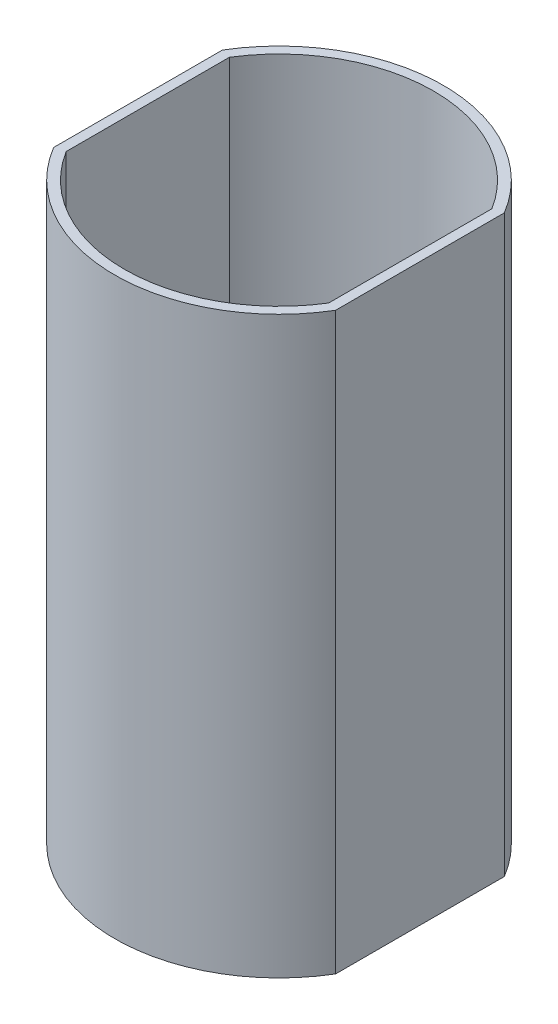
from build123d import *

# Parameters (mm, degrees)
SKETCH1_R           = 30.3
BOSS_EXTRUDE1_DEPTH = 106
CUT_EXTRUDE1_REACH  = 108
SKETCH2_W           = 5
SKETCH2_H           = 60.6
SHELL1_T            = -1.8
CUT_EXTRUDE2_REACH  = 3.8
SKETCH3_R           = 1.75
SKETCH3_R_2         = 7.5
SKETCH4_W           = 7
SKETCH4_H           = 8
SKETCH4_R           = 1.75
BOSS_EXTRUDE2_DEPTH = 15


with BuildPart() as part:
    # Sketch1 → Boss-Extrude1 (new body)
    with BuildSketch(Plane(origin=(0, 0, 0), x_dir=(1, 0, 0), z_dir=(0, 1, 0))):
        Circle(SKETCH1_R)
    extrude(amount=BOSS_EXTRUDE1_DEPTH)

    # Sketch2 → Cut-Extrude1 (cut, up to next)
    with BuildSketch(Plane(origin=(0, 106, 0), x_dir=(1, 0, 0), z_dir=(0, 1, 0)), mode=Mode.PRIVATE) as cut_extrude1_sk1:
        with Locations((28.5, 0)):
            Rectangle(SKETCH2_W, SKETCH2_H)
    cut_extrude1_tool1 = extrude(cut_extrude1_sk1.sketch, amount=-CUT_EXTRUDE1_REACH, mode=Mode.PRIVATE) & part.part
    add(cut_extrude1_tool1.solids().sort_by_distance((28.5, 106, 0))[0], mode=Mode.SUBTRACT)
    # Sketch2 → Cut-Extrude1 (cut, up to next)
    with BuildSketch(Plane(origin=(0, 106, 0), x_dir=(1, 0, 0), z_dir=(0, 1, 0)), mode=Mode.PRIVATE) as cut_extrude1_sk2:
        with Locations((-28.5, 0)):
            Rectangle(SKETCH2_W, SKETCH2_H)
    cut_extrude1_tool2 = extrude(cut_extrude1_sk2.sketch, amount=-CUT_EXTRUDE1_REACH, mode=Mode.PRIVATE) & part.part
    add(cut_extrude1_tool2.solids().sort_by_distance((-28.5, 106, 0))[0], mode=Mode.SUBTRACT)

    # Shell1
    shell1_openings = [part.faces().sort_by_distance(p)[0] for p in [
        (0, 106, 0),
    ]]
    offset(amount=SHELL1_T, openings=shell1_openings, kind=Kind.INTERSECTION)

    # Sketch3 → Cut-Extrude2 (cut, up to next)
    with BuildSketch(Plane(origin=(0, 1.8, 0), x_dir=(1, 0, 0), z_dir=(0, 1, 0)), mode=Mode.PRIVATE) as cut_extrude2_sk1:
        with Locations((0, 23.5)):
            Circle(SKETCH3_R)
    cut_extrude2_tool1 = extrude(cut_extrude2_sk1.sketch, amount=-CUT_EXTRUDE2_REACH, mode=Mode.PRIVATE) & part.part
    add(cut_extrude2_tool1.solids().sort_by_distance((0, 1.8, -23.5))[0], mode=Mode.SUBTRACT)
    # Sketch3 → Cut-Extrude2 (cut, up to next)
    with BuildSketch(Plane(origin=(0, 1.8, 0), x_dir=(1, 0, 0), z_dir=(0, 1, 0)), mode=Mode.PRIVATE) as cut_extrude2_sk2:
        with Locations((0, -23.5)):
            Circle(SKETCH3_R)
    cut_extrude2_tool2 = extrude(cut_extrude2_sk2.sketch, amount=-CUT_EXTRUDE2_REACH, mode=Mode.PRIVATE) & part.part
    add(cut_extrude2_tool2.solids().sort_by_distance((0, 1.8, 23.5))[0], mode=Mode.SUBTRACT)
    # Sketch3 → Cut-Extrude2 (cut, up to next)
    with BuildSketch(Plane(origin=(0, 1.8, 0), x_dir=(1, 0, 0), z_dir=(0, 1, 0)), mode=Mode.PRIVATE) as cut_extrude2_sk3:
        Circle(SKETCH3_R_2)
    cut_extrude2_tool3 = extrude(cut_extrude2_sk3.sketch, amount=-CUT_EXTRUDE2_REACH, mode=Mode.PRIVATE) & part.part
    add(cut_extrude2_tool3.solids().sort_by_distance((0, 1.8, 0))[0], mode=Mode.SUBTRACT)

    # Sketch4 → Boss-Extrude2 (add)
    with BuildSketch(Plane(origin=(0, 1.8, 0), x_dir=(1, 0, 0), z_dir=(0, 1, 0))):
        with Locations((0, 24.5)):
            Rectangle(SKETCH4_W, SKETCH4_H)
        with Locations((0, 23.5)):
            Circle(SKETCH4_R, mode=Mode.SUBTRACT)
        with Locations((0, -24.5)):
            Rectangle(SKETCH4_W, SKETCH4_H)
        with Locations((0, -23.5)):
            Circle(SKETCH4_R, mode=Mode.SUBTRACT)
    extrude(amount=BOSS_EXTRUDE2_DEPTH)


solid = part.part
